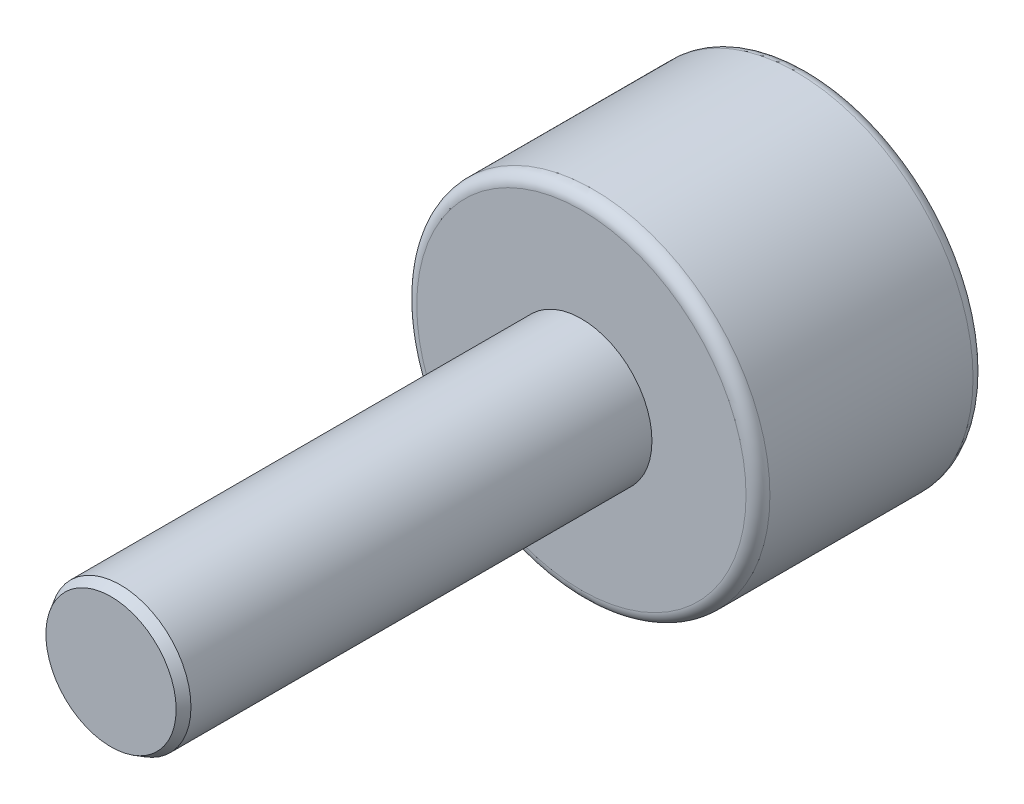
from build123d import *

# Parameters (mm, degrees)
CUT_EXTRUDE1_DEPTH  = 2.54
SKETCH3_R           = 1.5
BOSS_EXTRUDE1_DEPTH = 10
CHAMFER1_SIZE       = 0.2
CHAMFER1_SIZE2      = 0.115470054


with BuildPart() as part:
    # Sketch1 → Revolve1 (revolve)
    with BuildSketch(Plane(origin=(0, 0, 0), x_dir=(1, 0, 0), z_dir=(0, 1, 0))):
        with BuildLine():
            Line((0, 0), (3.5, 0))
            ThreePointArc((3.5, 0), (3.679605122, -0.074394878), (3.754, -0.254))
            Line((3.754, -0.254), (3.754, -4.572))
            ThreePointArc((3.754, -4.572), (3.679605122, -4.751605122), (3.5, -4.826))
            Line((3.5, -4.826), (0, -4.826))
            Line((0, -4.826), (0, 0))
        make_face()
    revolve(axis=Axis((0, 0, 0), (0, 0, -1)))

    # Sketch2 → Cut-Extrude1 (cut)
    with BuildSketch(Plane(origin=(0, 0, 0), x_dir=(-1, 0, 0), z_dir=(0, 0, -1))):
        Polygon((0, 2.55), (-2.20836478, 1.275), (-2.20836478, -1.275), (0, -2.55), (2.20836478, -1.275), (2.20836478, 1.275), align=None)
    extrude(amount=-CUT_EXTRUDE1_DEPTH, mode=Mode.SUBTRACT)

    # Sketch3 → Boss-Extrude1 (add)
    with BuildSketch(Plane.XY.offset(4.826)):
        Circle(SKETCH3_R)
    extrude(amount=BOSS_EXTRUDE1_DEPTH)

    # Chamfer1
    chamfer1_edges = [part.edges().sort_by_distance(p)[0] for p in [
        (-1.5, 0, 14.826),
    ]]
    chamfer1_side = [part.faces().sort_by_distance(p)[0] for p in [
        (-1.5, 0, 9.826),
    ]]
    chamfer(chamfer1_edges, length=CHAMFER1_SIZE, length2=CHAMFER1_SIZE2, reference=chamfer1_side[0])


solid = part.part
